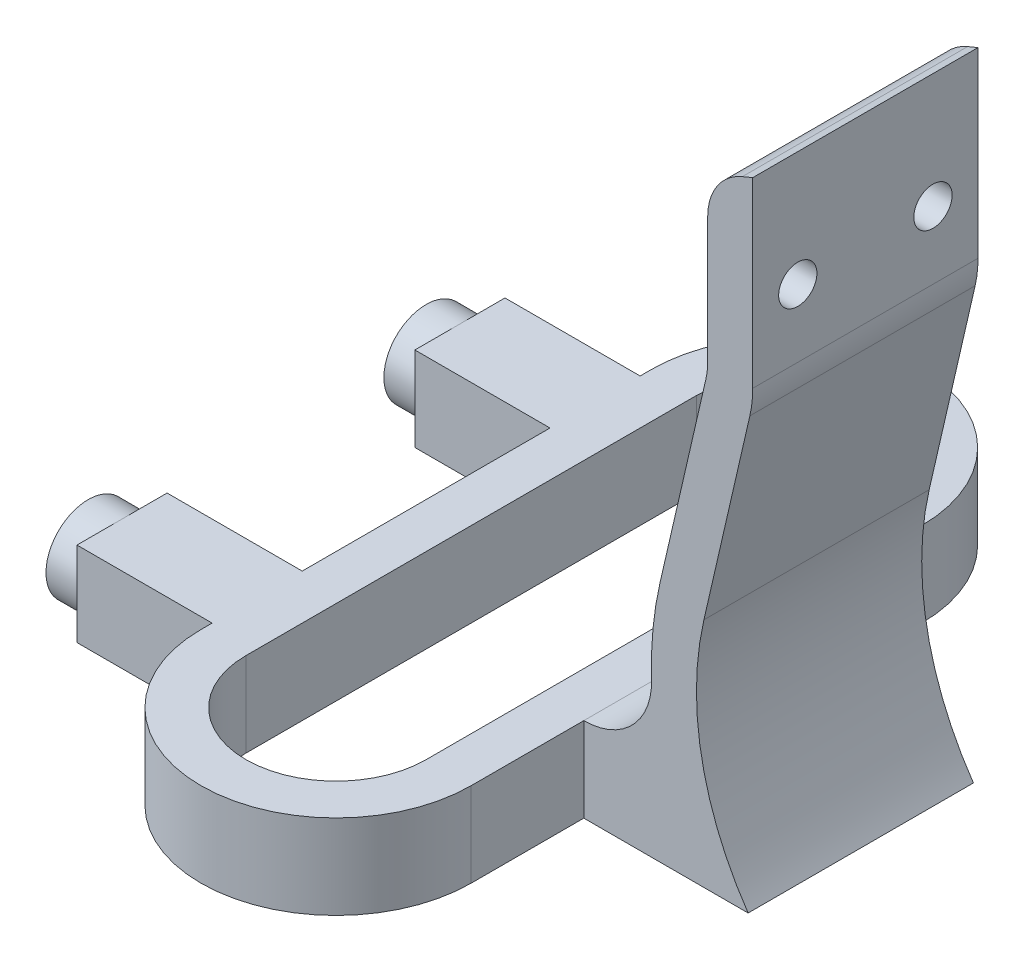
from build123d import *

# Parameters (mm, degrees)
BOSS_EXTRUDE1_DEPTH      = 3.75
SKETCH2_R                = 3.75
BOSS_EXTRUDE2_DEPTH      = 3
M4_CLEARANCE_HOLE1_D     = 4.5
M4_CLEARANCE_HOLE1_DEPTH = 10
M4_CLEARANCE_HOLE1_TIP   = 1.351936393
CUT_EXTRUDE1_DEPTH       = 33
CUT_EXTRUDE1_DEPTH_BACK  = 33
BOSS_EXTRUDE3_DEPTH      = 10
M3_CLEARANCE_HOLE1_D     = 3.4
M3_CLEARANCE_HOLE1_DEPTH = 10
M3_CLEARANCE_HOLE1_TIP   = 1.021463052


with BuildPart() as part:
    # Sketch1 → Boss-Extrude1 (new body, symmetric)
    with BuildSketch(Plane(origin=(0, 0, 0), x_dir=(1, 0, 0), z_dir=(0, 1, 0))):
        with BuildLine():
            Line((0, -11), (12, -11))
            Line((12, -11), (12, 11))
            Line((12, 11), (0, 11))
            Line((0, 11), (0, 19))
            Line((0, 19), (12, 19))
            Line((12, 19), (12, 20))
            ThreePointArc((12, 20), (24, 32), (36, 20))
            Line((36, 20), (36, 10))
            Line((36, 10), (55, 10))
            Line((55, 10), (55, -10))
            Line((55, -10), (36, -10))
            Line((36, -10), (36, -20))
            ThreePointArc((36, -20), (24, -32), (12, -20))
            Line((12, -20), (12, -19))
            Line((12, -19), (0, -19))
            Line((0, -19), (0, -11))
        make_face()
        with BuildLine():
            Line((32, 20), (32, -20))
            ThreePointArc((32, -20), (24, -28), (16, -20))
            Line((16, -20), (16, 20))
            ThreePointArc((16, 20), (24, 28), (32, 20))
        make_face(mode=Mode.SUBTRACT)
    extrude(amount=BOSS_EXTRUDE1_DEPTH, both=True)

    # Sketch2 → Boss-Extrude2 (add)
    with BuildSketch(Plane.ZY):
        with Locations((-15, 0)):
            Circle(SKETCH2_R)
        with Locations((15, 0)):
            Circle(SKETCH2_R)
    extrude(amount=BOSS_EXTRUDE2_DEPTH)

    # M4 Clearance Hole1
    with Locations(Plane.ZY.offset(3)):
        with Locations((-15, 0), (15, 0)):
            Hole(M4_CLEARANCE_HOLE1_D / 2, depth=M4_CLEARANCE_HOLE1_DEPTH)
            with Locations((0, 0, -(M4_CLEARANCE_HOLE1_DEPTH + M4_CLEARANCE_HOLE1_TIP / 2))):  # 118° drill point
                Cone(0, M4_CLEARANCE_HOLE1_D / 2, M4_CLEARANCE_HOLE1_TIP, mode=Mode.SUBTRACT)

    # Sketch6 → Cut-Extrude1 (cut, two sides)
    with BuildSketch(Plane.XY) as cut_extrude1_sk:
        with BuildLine():
            Line((53.548387097, -7.31769585), (58.512723929, -6.476790348))
            Line((58.512723929, -6.476790348), (58.512723929, 16.833295116))
            Line((58.512723929, 16.833295116), (46.662820439, 16.833295116))
            ThreePointArc((46.662820439, 16.833295116), (46.996356715, 3.87133796), (53.548387097, -7.31769585))
        make_face()
    extrude(amount=CUT_EXTRUDE1_DEPTH, mode=Mode.SUBTRACT)
    extrude(cut_extrude1_sk.sketch, amount=-CUT_EXTRUDE1_DEPTH_BACK, mode=Mode.SUBTRACT)

    # Sketch7 → Boss-Extrude3 (add, symmetric)
    with BuildSketch(Plane.XY):
        with BuildLine():
            Line((46.662820439, 16.833295116), (50.743158051, 34.556424956))
            ThreePointArc((50.743158051, 34.556424956), (50.934151856, 35.670993937), (50.998088989, 36.8))
            Line((50.998088989, 36.8), (50.998088989, 53))
            Line((50.998088989, 53), (50.075012066, 52.615384615))
            ThreePointArc((50.075012066, 52.615384615), (47.837837517, 50.773500981), (46.998088989, 48))
            Line((46.998088989, 48), (46.998088989, 36.8))
            ThreePointArc((46.998088989, 36.8), (46.959726709, 36.122596362), (46.845130426, 35.453854973))
            Line((46.845130426, 35.453854973), (42.764792814, 17.730725133))
            ThreePointArc((42.764792814, 17.730725133), (42.138360124, 13.877927021), (42.017467452, 9.976407294))
            ThreePointArc((42.017467452, 9.976407294), (40.329493687, 5.586764491), (36, 3.75))
            Line((36, 3.75), (47.031269556, 3.75))
            ThreePointArc((47.031269556, 3.75), (46.010304001, 10.268083427), (46.662820439, 16.833295116))
        make_face()
    extrude(amount=BOSS_EXTRUDE3_DEPTH, both=True)

    # M3 Clearance Hole1
    with Locations(Plane.ZY.offset(-46.998088989)):
        with Locations((-6, 42.8), (6, 42.8)):
            Hole(M3_CLEARANCE_HOLE1_D / 2, depth=M3_CLEARANCE_HOLE1_DEPTH)
            with Locations((0, 0, -(M3_CLEARANCE_HOLE1_DEPTH + M3_CLEARANCE_HOLE1_TIP / 2))):  # 118° drill point
                Cone(0, M3_CLEARANCE_HOLE1_D / 2, M3_CLEARANCE_HOLE1_TIP, mode=Mode.SUBTRACT)


solid = part.part
